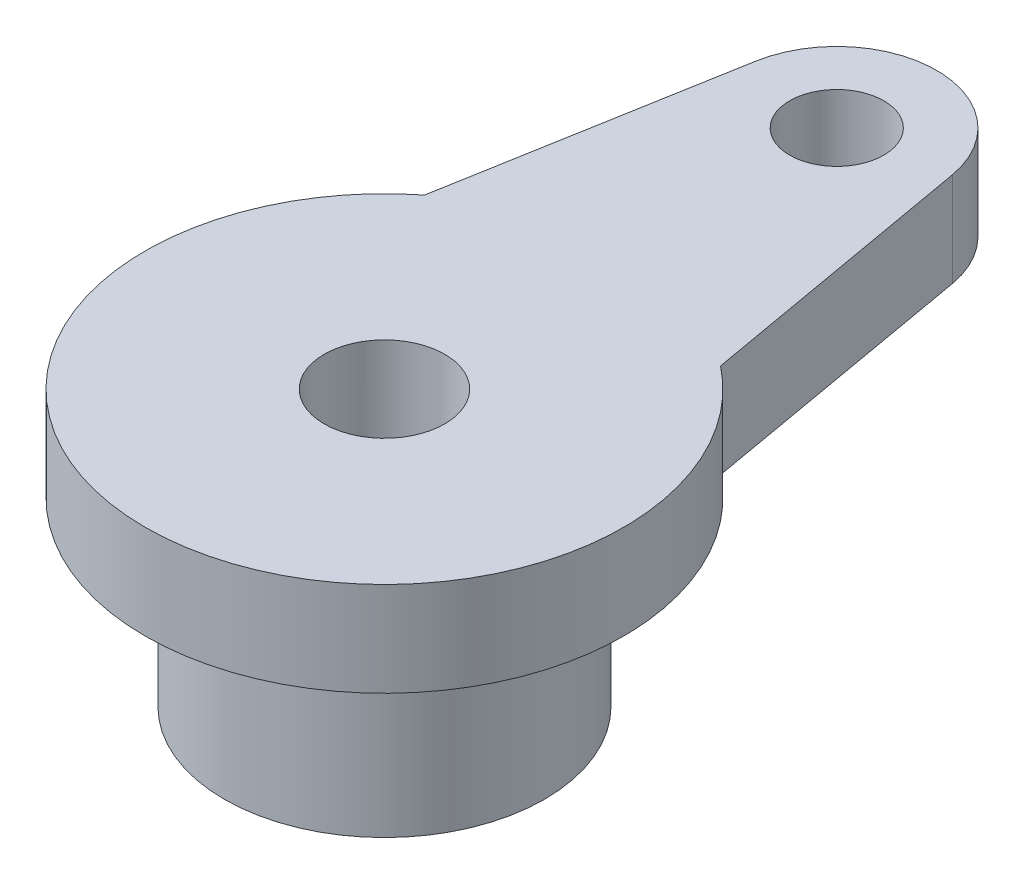
from build123d import *

# Parameters (mm, degrees)
BASES_R             = 6.35
BASE_DEPTH          = 7.3
HORN_HALF_DEPTH     = 2.5
TOOTH_DEPTH         = 3
TOOTH_CP_COUNT      = 26
BOTTOM_START        = -3
BOTTOMBORES_R       = 2.7
BOTTOM_BORE_DEPTH   = 3
HOLDINGSHAFTS_R     = 6.35
HOLDINGSHAFTS_R_2   = 4.25
HOLDING_SHAFT_DEPTH = 4.8
HORNATTACHS_R       = 1.25
CUT_EXTRUDE_1_DEPTH = 8.3
TOPBORES_R          = 1.6
CUT_EXTRUDE_2_DEPTH = 8.3


with BuildPart() as part:
    # BaseS → BASE (new body)
    with BuildSketch(Plane(origin=(0, 0, 0), x_dir=(1, 0, 0), z_dir=(0, 1, 0))):
        Circle(BASES_R)
    extrude(amount=BASE_DEPTH)

    # HornHalfS → HORN HALF (add)
    with BuildSketch(Plane(origin=(0, 7.3, 0), x_dir=(1, 0, 0), z_dir=(0, 1, 0))):
        with BuildLine():
            Line((-2.609740545, 12.460167671), (-3.926899835, 4.990186137))
            ThreePointArc((-3.926899835, 4.990186137), (0, 6.35), (3.926899835, 4.990186137))
            Line((3.926899835, 4.990186137), (2.609740545, 12.460167671))
            ThreePointArc((2.609740545, 12.460167671), (0, 14.65), (-2.609740545, 12.460167671))
        make_face()
    extrude(amount=-HORN_HALF_DEPTH)

    # ToothS → TOOTH (cut)
    with BuildSketch(Plane.XZ):
        with BuildLine():
            Line((0, -3), (0.262459231, -2.687213269))
            ThreePointArc((0.262459231, -2.687213269), (0, -2.7), (-0.262459231, -2.687213269))
            Line((-0.262459231, -2.687213269), (0, -3))
        make_face()
    tooth = extrude(amount=-TOOTH_DEPTH, mode=Mode.SUBTRACT)

    # TOOTH CP: TOOTH ×26 about axis
    tooth_cp_axis = Axis((0, 0, 0), (0, 1, 0))
    for i in range(1, TOOTH_CP_COUNT):
        add(tooth.rotate(tooth_cp_axis, i * 360 / TOOTH_CP_COUNT), mode=Mode.SUBTRACT)

    # BottomBoreS → BOTTOM BORE (cut)
    with BuildSketch(Plane(origin=(0, 0, 0), x_dir=(-1, 0, 0), z_dir=(0, -1, 0)).offset(BOTTOM_START)):
        Circle(BOTTOMBORES_R)
    extrude(amount=BOTTOM_BORE_DEPTH, mode=Mode.SUBTRACT)

    # HoldingShaftS → HOLDING SHAFT (cut)
    with BuildSketch(Plane.XZ):
        Circle(HOLDINGSHAFTS_R)
        Circle(HOLDINGSHAFTS_R_2, mode=Mode.SUBTRACT)
    extrude(amount=-HOLDING_SHAFT_DEPTH, mode=Mode.SUBTRACT)

    # HornAttachS → 除料-伸長1 (cut, through all)
    with BuildSketch(Plane(origin=(0, 7.3, 0), x_dir=(1, 0, 0), z_dir=(0, 1, 0))):
        with Locations((0, 12)):
            Circle(HORNATTACHS_R)
    extrude(amount=-CUT_EXTRUDE_1_DEPTH, mode=Mode.SUBTRACT)

    # TopBoreS → 除料-伸長2 (cut, through all)
    with BuildSketch(Plane(origin=(0, 7.3, 0), x_dir=(1, 0, 0), z_dir=(0, 1, 0))):
        Circle(TOPBORES_R)
    extrude(amount=-CUT_EXTRUDE_2_DEPTH, mode=Mode.SUBTRACT)


solid = part.part
